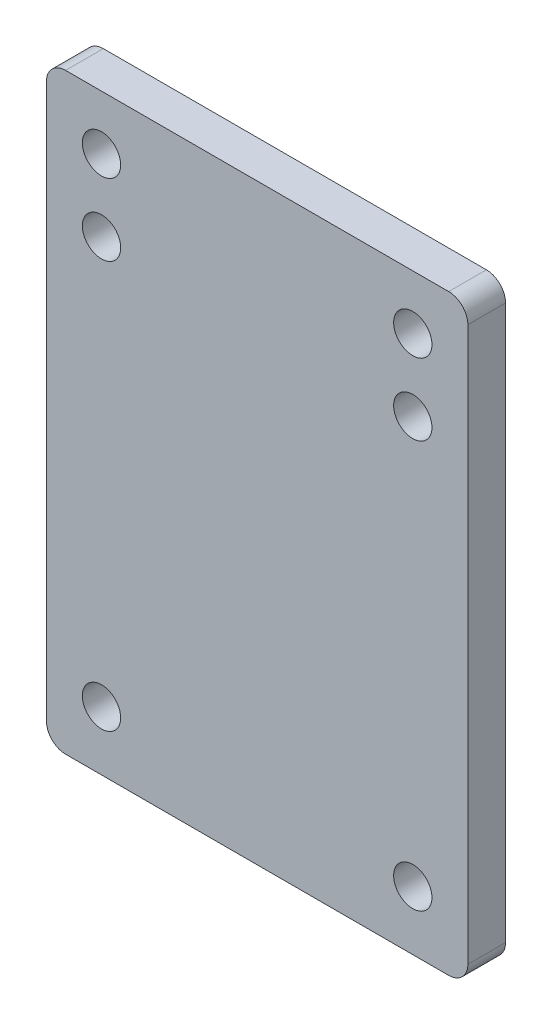
from build123d import *

# Parameters (mm, degrees)
SKIZZE1_R                       = 2.54
AUFSATZ_LINEAR_AUSTRAGEN1_DEPTH = 5


with BuildPart() as part:
    # Skizze1 → Aufsatz-Linear austragen1 (new body)
    with BuildSketch(Plane.XY):
        with BuildLine():
            Line((9.866806535, -39.166387358), (26.373711346, -39.166387358))
            add(Edge.make_bspline(
                [(26.373711346, -39.166387358), (28.913711346, -39.166387358), (28.913711346, -36.622901599)],
                knots=[3.141592654, 3.141592654, 3.141592654, 4.71238898, 4.71238898, 4.71238898], degree=2, weights=[1, 0.707106781, 1]))
            Line((28.913711346, -36.622901599), (28.913711346, 36.821129628))
            ThreePointArc((28.913711346, 36.821129628), (28.169762571, 38.617180852), (26.373711346, 39.361129628))
            Line((26.373711346, 39.361129628), (-24.426288654, 39.361129628))
            ThreePointArc((-24.426288654, 39.361129628), (-26.222339878, 38.617180852), (-26.966288654, 36.821129628))
            Line((-26.966288654, 36.821129628), (-26.966288654, -36.622901599))
            add(Edge.make_bspline(
                [(-26.966288654, -36.622901599), (-26.966288654, -39.166387358), (-24.426288654, -39.166387358)],
                knots=[1.570796327, 1.570796327, 1.570796327, 3.141592654, 3.141592654, 3.141592654], degree=2, weights=[1, 0.707106781, 1]))
            Line((-24.426288654, -39.166387358), (-7.919383842, -39.166387358))
            add(Edge.make_bspline(
                [(-7.919383842, -39.166387358), (-7.896041529, -39.166387358), (-7.872713398, -39.165529461)],
                knots=[0.586855187, 0.586855187, 0.586855187, 0.623588271, 0.623588271, 0.623588271], degree=2, weights=[1, 0.99983134, 1]))
            Line((-7.872713398, -39.165529461), (9.866806535, -39.166387358))
        make_face()
        with Locations((-19.663788654, -31.343187358)):
            Circle(SKIZZE1_R, mode=Mode.SUBTRACT)
        with Locations((21.611211346, -31.343187358)):
            Circle(SKIZZE1_R, mode=Mode.SUBTRACT)
        with Locations((21.611211346, 32.156812642)):
            Circle(SKIZZE1_R, mode=Mode.SUBTRACT)
        with Locations((21.611211346, 22.631812642)):
            Circle(SKIZZE1_R, mode=Mode.SUBTRACT)
        with Locations((-19.663788654, 22.631812642)):
            Circle(SKIZZE1_R, mode=Mode.SUBTRACT)
        with Locations((-19.663788654, 32.156812642)):
            Circle(SKIZZE1_R, mode=Mode.SUBTRACT)
    extrude(amount=AUFSATZ_LINEAR_AUSTRAGEN1_DEPTH)


solid = part.part
